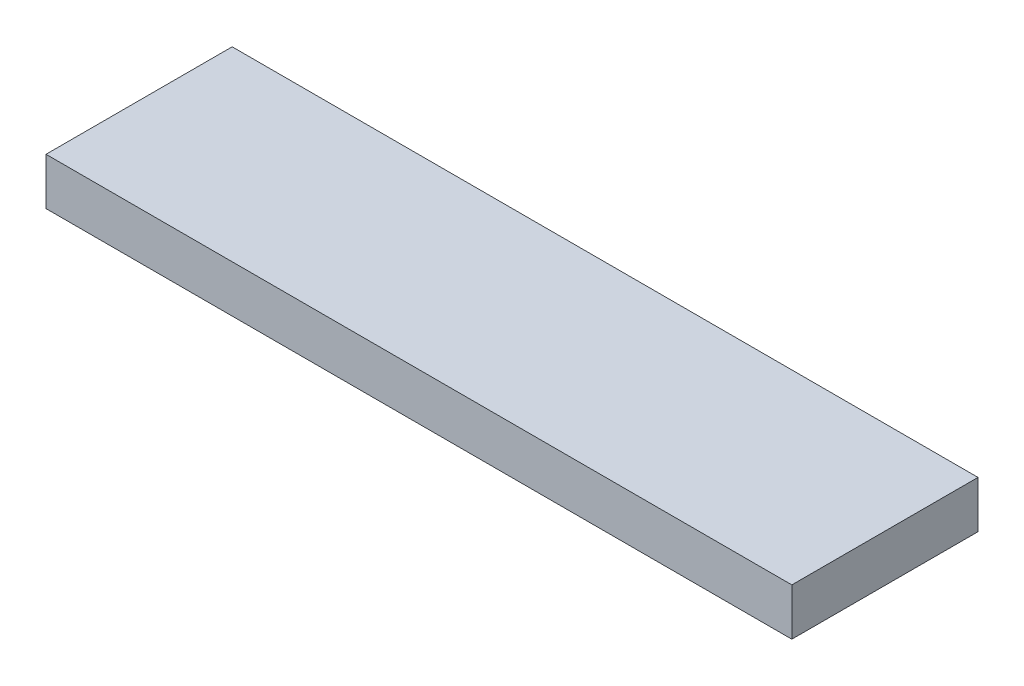
from build123d import *

# Parameters (mm, degrees)
SKETCH1_W           = 158.491546694
SKETCH1_H           = 39.560291276
BOSS_EXTRUDE1_DEPTH = 10


with BuildPart() as part:
    # Sketch1 → Boss-Extrude1 (new body)
    with BuildSketch(Plane(origin=(0, 0, 0), x_dir=(1, 0, 0), z_dir=(0, 1, 0))):
        Rectangle(SKETCH1_W, SKETCH1_H)
    extrude(amount=BOSS_EXTRUDE1_DEPTH)


solid = part.part
